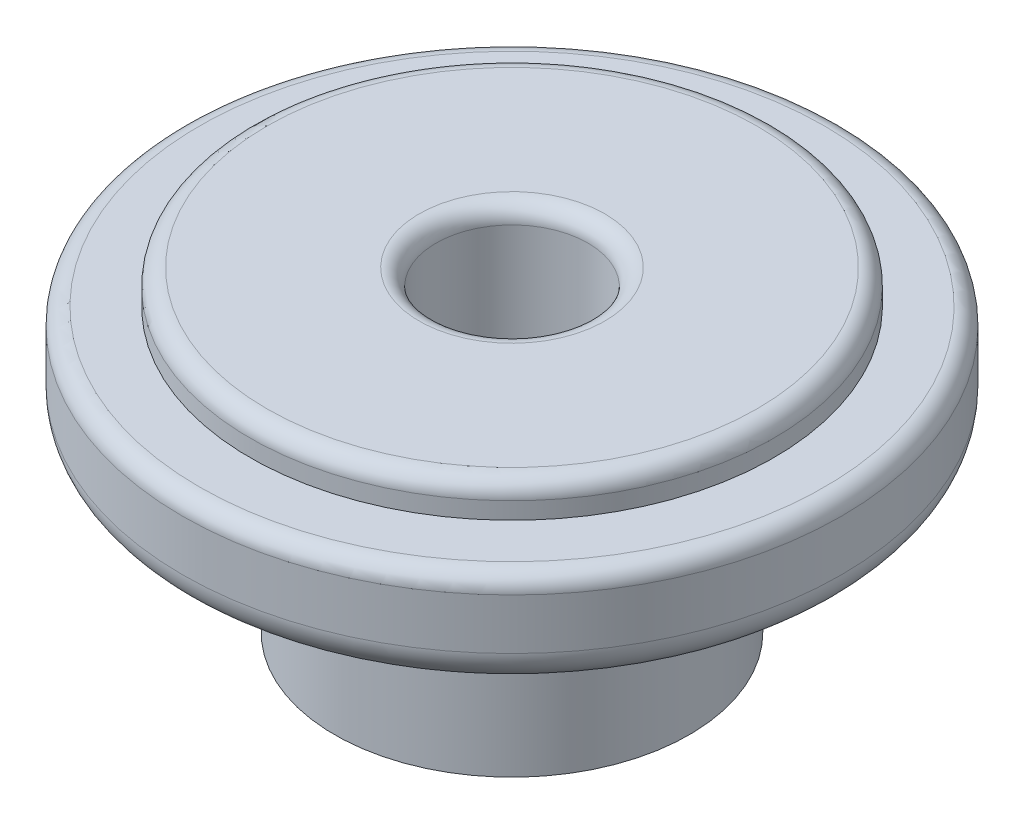
from build123d import *

# Parameters (mm, degrees)
FILLET1_R = 0.5


with BuildPart() as part:
    # Sketch1 → Revolve1 (revolve)
    with BuildSketch(Plane.XY):
        with BuildLine():
            Line((-2.2479, 0), (-2.2479, 9.35))
            Line((-2.2479, 9.35), (-7.7479, 9.35))
            Line((-7.7479, 9.35), (-7.7479, 8.35))
            Line((-7.7479, 8.35), (-9.7479, 8.35))
            Line((-9.7479, 8.35), (-9.7479, 6.35))
            ThreePointArc((-9.7479, 6.35), (-8.7479, 5.35), (-7.7479, 6.35))
            Line((-7.7479, 6.35), (-5.2479, 6.35))
            Line((-5.2479, 6.35), (-5.2479, 0))
            Line((-5.2479, 0), (-2.2479, 0))
        make_face()
    revolve(axis=Axis((0, 0, 0), (0, 1, 0)))

    # Fillet1
    fillet1_edges = [part.edges().sort_by_distance(p)[0] for p in [
        (7.7479, 9.35, 0),
        (2.2479, 9.35, 0),
        (9.7479, 8.35, 0),
    ]]
    fillet(fillet1_edges, radius=FILLET1_R)


solid = part.part
